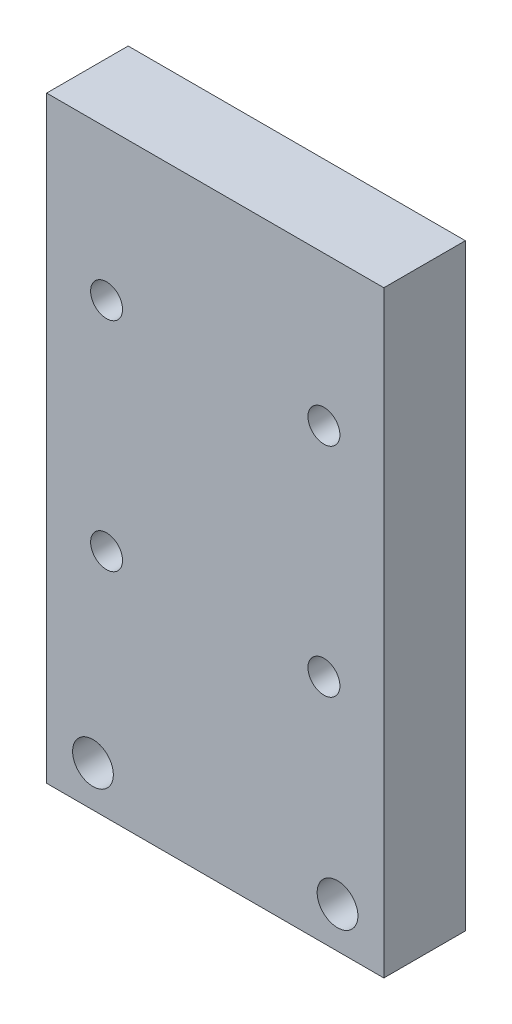
from build123d import *

# Parameters (mm, degrees)
ESQUISSE1_W             = 24.82
ESQUISSE1_H             = 44
ESQUISSE1_R             = 1.5
BOSS_EXTRU_1_DEPTH      = 6
ESQUISSE2_R             = 1.175
ENL_V_MAT_EXTRU_1_DEPTH = 6


with BuildPart() as part:
    # Esquisse1 → Boss.-Extru.1 (new body)
    with BuildSketch(Plane.XY):
        with Locations((-51.605872064, 20.185897225)):
            Rectangle(ESQUISSE1_W, ESQUISSE1_H)
        with Locations((-60.605872064, 1.185897225)):
            Circle(ESQUISSE1_R, mode=Mode.SUBTRACT)
        with Locations((-42.605872064, 1.185897225)):
            Circle(ESQUISSE1_R, mode=Mode.SUBTRACT)
    extrude(amount=BOSS_EXTRU_1_DEPTH)

    # Esquisse2 → Enlèv. mat.-Extru.1 (cut)
    with BuildSketch(Plane.XY.offset(6)):
        with Locations((-43.605872064, 31.185897225)):
            Circle(ESQUISSE2_R)
        with Locations((-59.605872064, 31.185897225)):
            Circle(ESQUISSE2_R)
        with Locations((-59.605872064, 15.185897225)):
            Circle(ESQUISSE2_R)
        with Locations((-43.605872064, 15.185897225)):
            Circle(ESQUISSE2_R)
    extrude(amount=-ENL_V_MAT_EXTRU_1_DEPTH, mode=Mode.SUBTRACT)


solid = part.part
